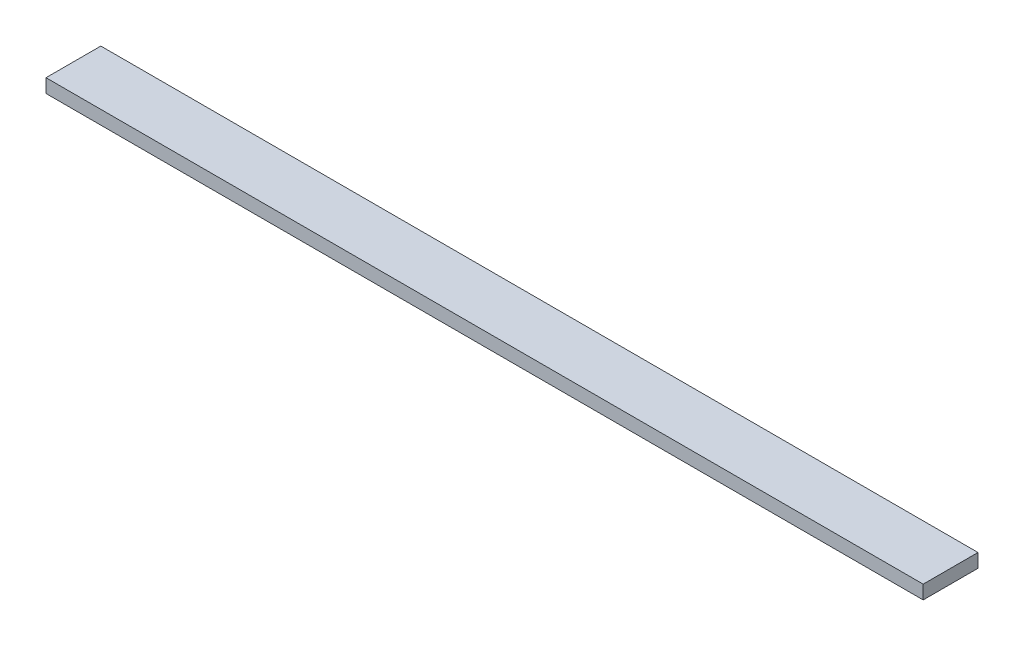
from build123d import *

# Parameters (mm, degrees)
SKETCH1_W           = 1
SKETCH1_H           = 0.25
BOSS_EXTRUDE1_DEPTH = 16
SCALE1_SCALE        = 25.4


with BuildPart() as part:
    # Sketch1 → Boss-Extrude1 (new body)
    with BuildSketch(Plane(origin=(0, 0, 0), x_dir=(0, 0, -1), z_dir=(1, 0, 0))):
        with Locations((0.5, 0.125)):
            Rectangle(SKETCH1_W, SKETCH1_H)
    extrude(amount=BOSS_EXTRUDE1_DEPTH)


with BuildPart() as part_1:
    # Scale1: scaled about (8, 0.125, -0.5)
    add(part.part.scale(SCALE1_SCALE).moved(Location((-195.2, -3.05, 12.2))))


solid = part_1.part
